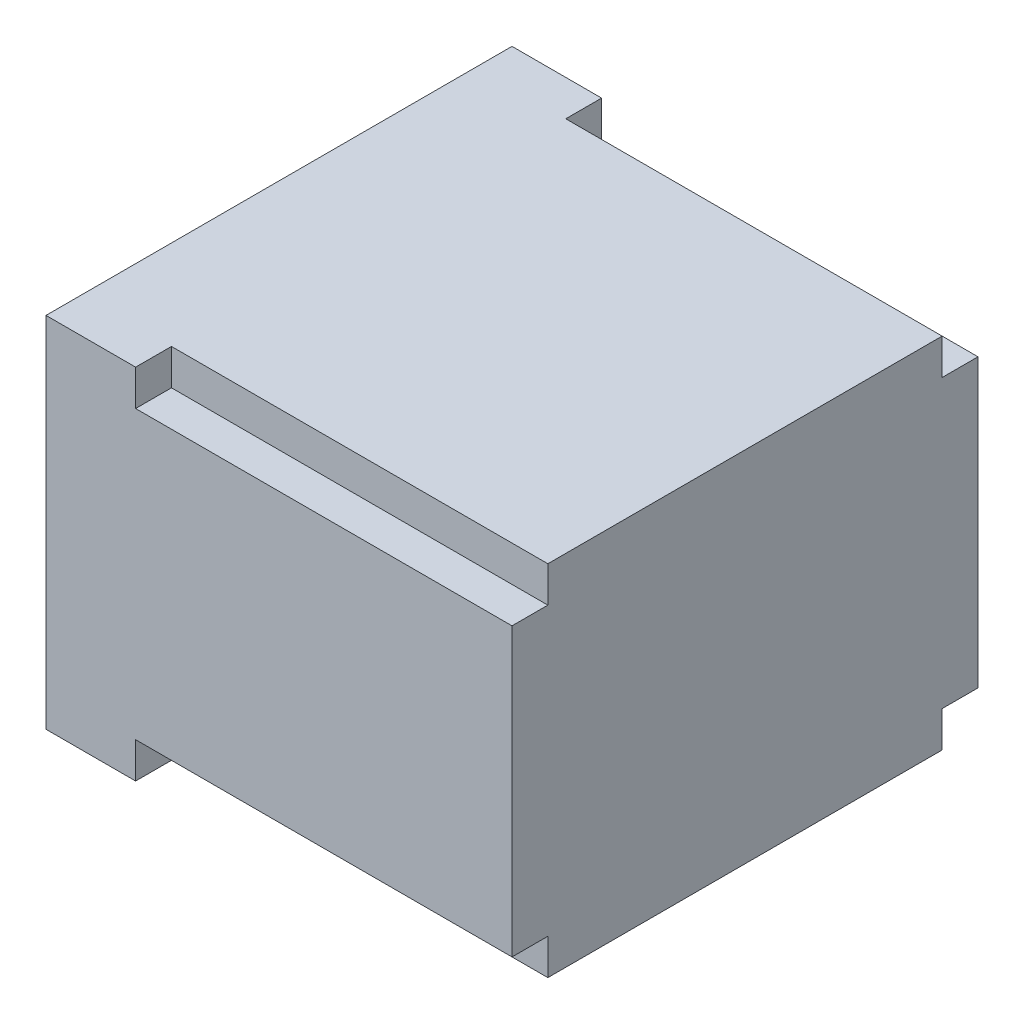
from build123d import *

# Parameters (mm, degrees)
SKETCH2_W           = 130
SKETCH2_H           = 130
BOSS_EXTRUDE1_DEPTH = 100
SKETCH3_W           = 104
SKETCH3_H           = 74
CUT_EXTRUDE1_DEPTH  = 127
SKETCH4_W           = 10
SKETCH4_H           = 10
CUT_EXTRUDE3_DEPTH  = 105
SKETCH5_W           = 104
SKETCH5_H           = 10
CUT_EXTRUDE4_DEPTH  = 127
SKETCH6_W           = 10
SKETCH6_H           = 74
CUT_EXTRUDE5_DEPTH  = 127
SKETCH7_R           = 1.75
CUT_EXTRUDE6_DEPTH  = 20
SKETCH8_W           = 3
SKETCH8_H           = 3
CUT_EXTRUDE7_DEPTH  = 5
SKETCH9_W           = 85
SKETCH9_H           = 60
BOSS_EXTRUDE2_DEPTH = 15
SKETCH11_W          = 85
SKETCH11_H          = 6
BOSS_EXTRUDE5_DEPTH = 5
SKETCH12_W          = 85
SKETCH12_H          = 3
CUT_EXTRUDE9_DEPTH  = 4
SKETCH13_W          = 82
SKETCH13_H          = 57
CUT_EXTRUDE10_DEPTH = 15
SKETCH15_W          = 3
SKETCH15_H          = 3
BOSS_EXTRUDE7_DEPTH = 5
SKETCH16_W          = 82
SKETCH16_H          = 2
BOSS_EXTRUDE8_DEPTH = 57
SKETCH17_W          = 77
SKETCH17_H          = 47
CUT_EXTRUDE11_DEPTH = 10
SKETCH19_W          = 7
SKETCH19_H          = 2
SKETCH19_H_2        = 1
BOSS_EXTRUDE9_DEPTH = 1
SKETCH21_W          = 3
SKETCH21_H          = 3
CUT_EXTRUDE15_DEPTH = 5


with BuildPart() as part:
    # Sketch2 → Boss-Extrude1 (new body)
    with BuildSketch(Plane(origin=(0, 0, 0), x_dir=(1, 0, 0), z_dir=(0, 1, 0))):
        with Locations((65, 65)):
            Rectangle(SKETCH2_W, SKETCH2_H)
    extrude(amount=BOSS_EXTRUDE1_DEPTH)

    # Sketch3 → Cut-Extrude1 (cut)
    with BuildSketch(Plane.ZY):
        with Locations((-65, 50)):
            Rectangle(SKETCH3_W, SKETCH3_H)
    extrude(amount=-CUT_EXTRUDE1_DEPTH, mode=Mode.SUBTRACT)

    # Sketch4 → Cut-Extrude3 (cut)
    with BuildSketch(Plane(origin=(130, 0, 0), x_dir=(0, 0, -1), z_dir=(1, 0, 0))):
        with Locations((5, 95)):
            Rectangle(SKETCH4_W, SKETCH4_H)
        with Locations((125, 95)):
            Rectangle(SKETCH4_W, SKETCH4_H)
        with Locations((5, 5)):
            Rectangle(SKETCH4_W, SKETCH4_H)
        with Locations((125, 5)):
            Rectangle(SKETCH4_W, SKETCH4_H)
    extrude(amount=-CUT_EXTRUDE3_DEPTH, mode=Mode.SUBTRACT)

    # Sketch5 → Cut-Extrude4 (cut)
    with BuildSketch(Plane.ZY):
        with Locations((-65, 92)):
            Rectangle(SKETCH5_W, SKETCH5_H)
        with Locations((-65, 8)):
            Rectangle(SKETCH5_W, SKETCH5_H)
    extrude(amount=-CUT_EXTRUDE4_DEPTH, mode=Mode.SUBTRACT)

    # Sketch6 → Cut-Extrude5 (cut)
    with BuildSketch(Plane.ZY):
        with Locations((-122, 50)):
            Rectangle(SKETCH6_W, SKETCH6_H)
        with Locations((-8, 50)):
            Rectangle(SKETCH6_W, SKETCH6_H)
    extrude(amount=-CUT_EXTRUDE5_DEPTH, mode=Mode.SUBTRACT)

    # Sketch7 → Cut-Extrude6 (cut)
    with BuildSketch(Plane.ZY):
        with Locations((-124, 94)):
            Circle(SKETCH7_R)
        with Locations((-6, 94)):
            Circle(SKETCH7_R)
        with Locations((-124, 6)):
            Circle(SKETCH7_R)
        with Locations((-6, 6)):
            Circle(SKETCH7_R)
    extrude(amount=-CUT_EXTRUDE6_DEPTH, mode=Mode.SUBTRACT)

    # Sketch8 → Cut-Extrude7 (cut)
    with BuildSketch(Plane.ZY):
        with Locations((-118.5, 88.5)):
            Rectangle(SKETCH8_W, SKETCH8_H)
        with Locations((-11.5, 88.5)):
            Rectangle(SKETCH8_W, SKETCH8_H)
        with Locations((-118.5, 11.5)):
            Rectangle(SKETCH8_W, SKETCH8_H)
        with Locations((-11.5, 11.5)):
            Rectangle(SKETCH8_W, SKETCH8_H)
    extrude(amount=-CUT_EXTRUDE7_DEPTH, mode=Mode.SUBTRACT)

    # Sketch9 → Boss-Extrude2 (add)
    with BuildSketch(Plane(origin=(0, 3, 0), x_dir=(1, 0, 0), z_dir=(0, 1, 0))):
        with Locations((42.5, 87)):
            Rectangle(SKETCH9_W, SKETCH9_H)
    extrude(amount=BOSS_EXTRUDE2_DEPTH)

    # Sketch11 → Boss-Extrude5 (add)
    with BuildSketch(Plane(origin=(0, 13, 0), x_dir=(1, 0, 0), z_dir=(0, 1, 0))):
        with Locations((42.5, 120)):
            Rectangle(SKETCH11_W, SKETCH11_H)
    extrude(amount=BOSS_EXTRUDE5_DEPTH)

    # Sketch12 → Cut-Extrude9 (cut)
    with BuildSketch(Plane(origin=(0, 18, 0), x_dir=(1, 0, 0), z_dir=(0, 1, 0))):
        with Locations((42.5, 121.5)):
            Rectangle(SKETCH12_W, SKETCH12_H)
    extrude(amount=-CUT_EXTRUDE9_DEPTH, mode=Mode.SUBTRACT)

    # Sketch13 → Cut-Extrude10 (cut)
    with BuildSketch(Plane(origin=(0, 18, 0), x_dir=(1, 0, 0), z_dir=(0, 1, 0))):
        with Locations((41, 88.5)):
            Rectangle(SKETCH13_W, SKETCH13_H)
    extrude(amount=-CUT_EXTRUDE10_DEPTH, mode=Mode.SUBTRACT)

    # Sketch15 → Boss-Extrude7 (add)
    with BuildSketch(Plane.ZY.offset(-5)):
        with Locations((-118.5, 11.5)):
            Rectangle(SKETCH15_W, SKETCH15_H)
    extrude(amount=BOSS_EXTRUDE7_DEPTH)

    # Sketch16 → Boss-Extrude8 (add)
    with BuildSketch(Plane(origin=(0, 0, -60), x_dir=(-1, 0, 0), z_dir=(0, 0, -1))):
        with Locations((-41, 17)):
            Rectangle(SKETCH16_W, SKETCH16_H)
        with Locations((-41, 12)):
            Rectangle(SKETCH16_W, SKETCH16_H)
    extrude(amount=BOSS_EXTRUDE8_DEPTH)

    # Sketch17 → Cut-Extrude11 (cut)
    with BuildSketch(Plane(origin=(0, 18, 0), x_dir=(1, 0, 0), z_dir=(0, 1, 0))):
        with Locations((38.5, 88.5)):
            Rectangle(SKETCH17_W, SKETCH17_H)
    extrude(amount=-CUT_EXTRUDE11_DEPTH, mode=Mode.SUBTRACT)

    # Sketch19 → Boss-Extrude9 (add)
    with BuildSketch(Plane.XY.offset(-117)):
        with Locations((3.5, 10)):
            Rectangle(SKETCH19_W, SKETCH19_H)
        with Locations((3.5, 13.5)):
            Rectangle(SKETCH19_W, SKETCH19_H_2)
    extrude(amount=BOSS_EXTRUDE9_DEPTH)

    # Sketch21 → Cut-Extrude15 (cut)
    with BuildSketch(Plane.ZY):
        with Locations((-118.5, 11.5)):
            Rectangle(SKETCH21_W, SKETCH21_H)
    extrude(amount=-CUT_EXTRUDE15_DEPTH, mode=Mode.SUBTRACT)


solid = part.part
